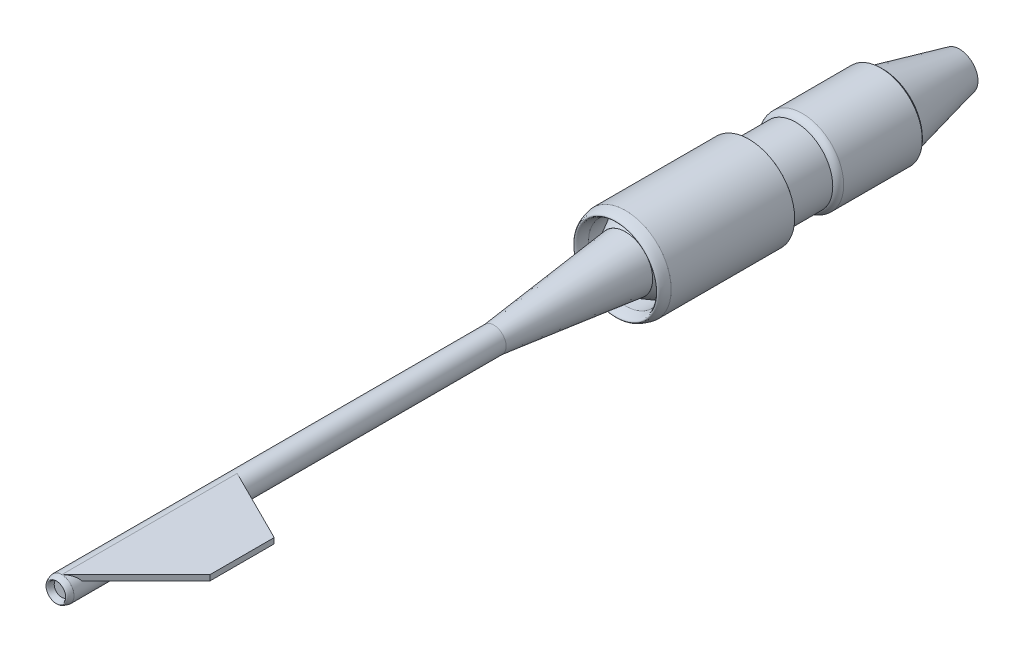
from build123d import *

# Parameters (mm, degrees)
SKETCH1_R           = 416.25
SKETCH1_R_2         = 337.5
BOSS_EXTRUDE1_DEPTH = 1125
SKETCH5_R           = 112.5
BOSS_EXTRUDE2_DEPTH = 3937.5
SKETCH15_R          = 337.5
BOSS_EXTRUDE5_DEPTH = 486
SKETCH16_R          = 376.875
BOSS_EXTRUDE6_DEPTH = 716
BOSS_EXTRUDE7_DEPTH = 50


with BuildPart() as part:
    # Sketch1 → Boss-Extrude1 (new body)
    with BuildSketch(Plane.XY):
        Circle(SKETCH1_R)
        Circle(SKETCH1_R_2, mode=Mode.SUBTRACT)
    extrude(amount=-BOSS_EXTRUDE1_DEPTH)

    # Sketch2 → Revolve1 (revolve)
    with BuildSketch(Plane(origin=(0, 0, 0), x_dir=(0, 0, -1), z_dir=(1, 0, 0))):
        with BuildLine():
            Line((0, 416.25), (0, 337.5))
            add(Edge.make_bspline(
                [(0, 337.5), (-180, 376.875), (0, 416.25)],
                knots=[0, 0, 0, 1, 1, 1], degree=2))
        make_face()
    revolve(axis=Axis((0, 0, 0), (0, 0, -1)))

    # Sketch18 → Revolve6 (revolve)
    with BuildSketch(Plane(origin=(0, 0, 0), x_dir=(0, 0, -1), z_dir=(1, 0, 0)), mode=Mode.PRIVATE) as revolve6_sk:
        Polygon((0, 247.5), (306.632414301, 416.25), (306.632414301, 247.5), align=None)
    revolve(revolve6_sk.sketch.rotate(Axis((0, 0, 0), (0, 0, -1)), 90), axis=Axis((0, 0, 0), (0, 0, -1)))



with BuildPart() as body_2:
    # Sketch4 → Revolve2 (revolve)
    with BuildSketch(Plane(origin=(0, 0, 0), x_dir=(1, 0, 0), z_dir=(0, 1, 0)), mode=Mode.PRIVATE) as revolve2_sk:
        Polygon((0, 0), (0, -1200), (112.5, -1200), (247.5, 0), align=None)
    revolve(revolve2_sk.sketch.rotate(Axis((0, 0, 0), (0, 0, 1)), 180), axis=Axis((0, 0, 0), (0, 0, 1)))

    # Sketch5 → Boss-Extrude2 (add)
    with BuildSketch(Plane.XY.offset(1200)):
        Circle(SKETCH5_R)
    extrude(amount=BOSS_EXTRUDE2_DEPTH)

    # Sketch14 → Revolve4 (revolve)
    with BuildSketch(Plane(origin=(0, 0, 0), x_dir=(0, 0, -1), z_dir=(1, 0, 0))):
        with BuildLine():
            add(Edge.make_bspline(
                [(-5137.5, 67.5), (-5237.5, 90), (-5137.5, 112.5)],
                knots=[0, 0, 0, 1, 1, 1], degree=2))
            Line((-5137.5, 112.5), (-5137.5, 67.5))
        make_face()
    revolve(axis=Axis((0, 0, 5137.5), (0, 0, 1)))

    # Sketch22 → Boss-Extrude7 (add)
    with BuildSketch(Plane(origin=(0, 112.486092048, 0), x_dir=(1, 0, 0), z_dir=(0, 1, 0))):
        Polygon((676.768925034, -4462.5), (1.768925034, -5137.5), (1.768925034, -3540), (676.768925034, -3877.5), align=None)
    extrude(amount=-BOSS_EXTRUDE7_DEPTH)


with BuildPart() as body_3:
    # Sketch15 → Boss-Extrude5 (new body)
    with BuildSketch(Plane(origin=(0, 0, -1125), x_dir=(-1, 0, 0), z_dir=(0, 0, -1))):
        with Locations(Location((0, 0, 0), (0, 0, 180))):
            Circle(SKETCH15_R)
    extrude(amount=BOSS_EXTRUDE5_DEPTH)

    # Sketch16 → Boss-Extrude6 (add)
    with BuildSketch(Plane(origin=(0, 0, -1611), x_dir=(-1, 0, 0), z_dir=(0, 0, -1))):
        with Locations(Location((0, 0, 0), (0, 0, 180))):
            Circle(SKETCH16_R)
    extrude(amount=BOSS_EXTRUDE6_DEPTH)

    # Sketch17 → Revolve5 (revolve)
    with BuildSketch(Plane(origin=(0, 0, 0), x_dir=(0, 0, -1), z_dir=(1, 0, 0)), mode=Mode.PRIVATE) as revolve5_sk:
        Polygon((2327, 0), (3043, 0), (3043, 168.75), (2327, 337.5), align=None)
    revolve(revolve5_sk.sketch.rotate(Axis((0, 0, -2327), (0, 0, -1)), 270), axis=Axis((0, 0, -2327), (0, 0, -1)))

    # Sketch19 → Revolve9 (revolve)
    with BuildSketch(Plane(origin=(0, 0, 0), x_dir=(0, 0, -1), z_dir=(1, 0, 0)), mode=Mode.PRIVATE) as revolve9_sk:
        with BuildLine():
            Line((1611, 337.5), (1551, 337.5))
            ThreePointArc((1551, 337.5), (1575.706535425, 365.253731733), (1611, 376.875))
            Line((1611, 376.875), (1611, 337.5))
        make_face()
    revolve(revolve9_sk.sketch.rotate(Axis((0, 0, -1611), (0, 0, 1)), 90), axis=Axis((0, 0, -1611), (0, 0, 1)))


with BuildPart() as part_1:
    add(part.part)

    add(body_3.part)  # Revolve11 merges body 3
    # Sketch20 → Revolve11 (revolve)
    with BuildSketch(Plane(origin=(0, 0, 0), x_dir=(0, 0, -1), z_dir=(1, 0, 0)), mode=Mode.PRIVATE) as revolve11_sk:
        with BuildLine():
            Line((1125, 337.5), (1125, 416.25))
            add(Edge.make_bspline(
                [(1155, 337.5), (1155, 382.589285714), (1125, 416.25)],
                knots=[0, 0, 0, 1, 1, 1], degree=2, weights=[1, 0.806097206, 1]))
            Line((1155, 337.5), (1125, 337.5))
        make_face()
    revolve(revolve11_sk.sketch.rotate(Axis((0, 0, -1125), (0, 0, -1)), 90), axis=Axis((0, 0, -1125), (0, 0, -1)))

    # Sketch21 → Revolve12 (revolve)
    with BuildSketch(Plane(origin=(0, 0, 0), x_dir=(0, 0, -1), z_dir=(1, 0, 0)), mode=Mode.PRIVATE) as revolve12_sk:
        with BuildLine():
            Line((2327, 337.5), (2327, 376.875))
            add(Edge.make_bspline(
                [(2327, 376.875), (2356.199972531, 357.1875), (2356.199972531, 330.618023234)],
                knots=[0, 0, 0, 1, 1, 1], degree=2, weights=[1, 0.829833158, 1]))
            Line((2356.199972531, 330.618023234), (2327, 337.5))
        make_face()
    revolve(revolve12_sk.sketch.rotate(Axis((0, 0, -2327), (0, 0, -1)), 90), axis=Axis((0, 0, -2327), (0, 0, -1)))


solid = Compound([body_2.part, part_1.part])
